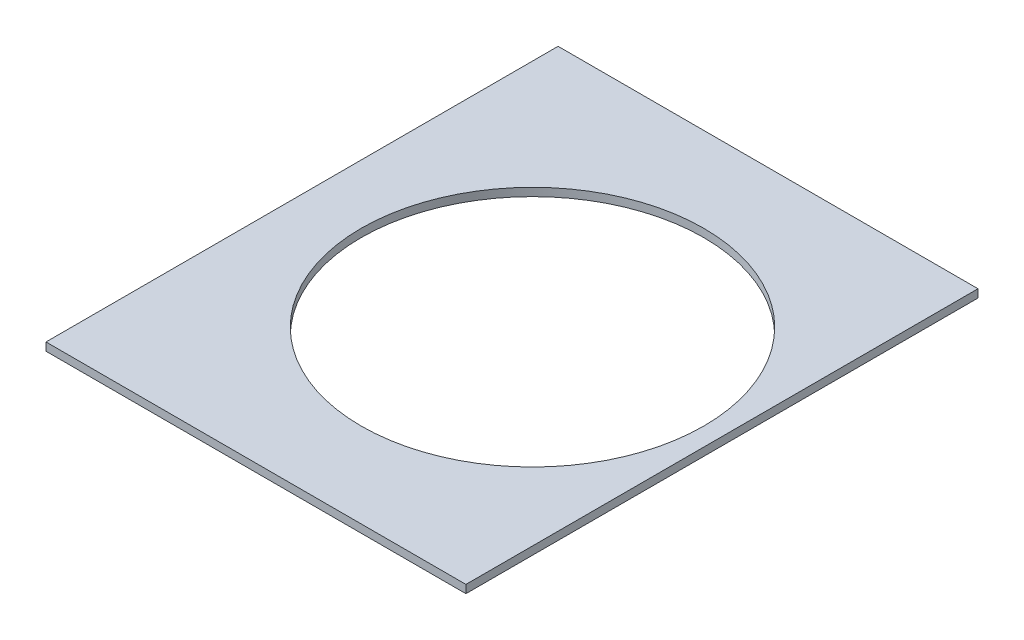
from build123d import *

# Parameters (mm, degrees)
BOSS_EXTRUDE1_DEPTH = 1.00076


with BuildPart() as part:
    # Sketch3 → Boss-Extrude1 (new body)
    with BuildSketch(Plane(origin=(0, 0, 0), x_dir=(1, 0, 0), z_dir=(0, 1, 0))):
        with BuildLine():
            Line((0, 63.5), (0, 0))
            Line((0, 0), (24.257, 0))
            Line((24.257, 0), (24.257, 10.953386454))
            ThreePointArc((24.257, 10.953386454), (7.334843244, 31.75), (24.257, 52.546613546))
            Line((24.257, 52.546613546), (24.257, 63.5))
            Line((24.257, 63.5), (0, 63.5))
        make_face()
        with BuildLine():
            Line((32.893, 10.953386454), (32.893, 0))
            Line((32.893, 0), (52.07, 0))
            Line((52.07, 0), (52.07, 63.5))
            Line((52.07, 63.5), (32.893, 63.5))
            Line((32.893, 63.5), (32.893, 52.546613546))
            ThreePointArc((32.893, 52.546613546), (45.050121485, 45.155768574), (49.815156756, 31.75))
            ThreePointArc((49.815156756, 31.75), (45.050121485, 18.344231426), (32.893, 10.953386454))
        make_face()
        with BuildLine():
            Line((28.575, 10.509843244), (28.575, 0))
            Line((28.575, 0), (32.893, 0))
            Line((32.893, 0), (32.893, 10.953386454))
            ThreePointArc((32.893, 10.953386454), (30.745360257, 10.621020011), (28.575, 10.509843244))
        make_face()
        with BuildLine():
            Line((24.257, 10.953386454), (24.257, 0))
            Line((24.257, 0), (28.575, 0))
            Line((28.575, 0), (28.575, 10.509843244))
            ThreePointArc((28.575, 10.509843244), (26.404639743, 10.621020011), (24.257, 10.953386454))
        make_face()
        with BuildLine():
            Line((32.893, 63.5), (28.575, 63.5))
            Line((28.575, 63.5), (28.575, 52.990156756))
            ThreePointArc((28.575, 52.990156756), (30.745360257, 52.878979989), (32.893, 52.546613546))
            Line((32.893, 52.546613546), (32.893, 63.5))
        make_face()
        with BuildLine():
            Line((28.575, 63.5), (24.257, 63.5))
            Line((24.257, 63.5), (24.257, 52.546613546))
            ThreePointArc((24.257, 52.546613546), (26.404639743, 52.878979989), (28.575, 52.990156756))
            Line((28.575, 52.990156756), (28.575, 63.5))
        make_face()
    extrude(amount=BOSS_EXTRUDE1_DEPTH)


solid = part.part
